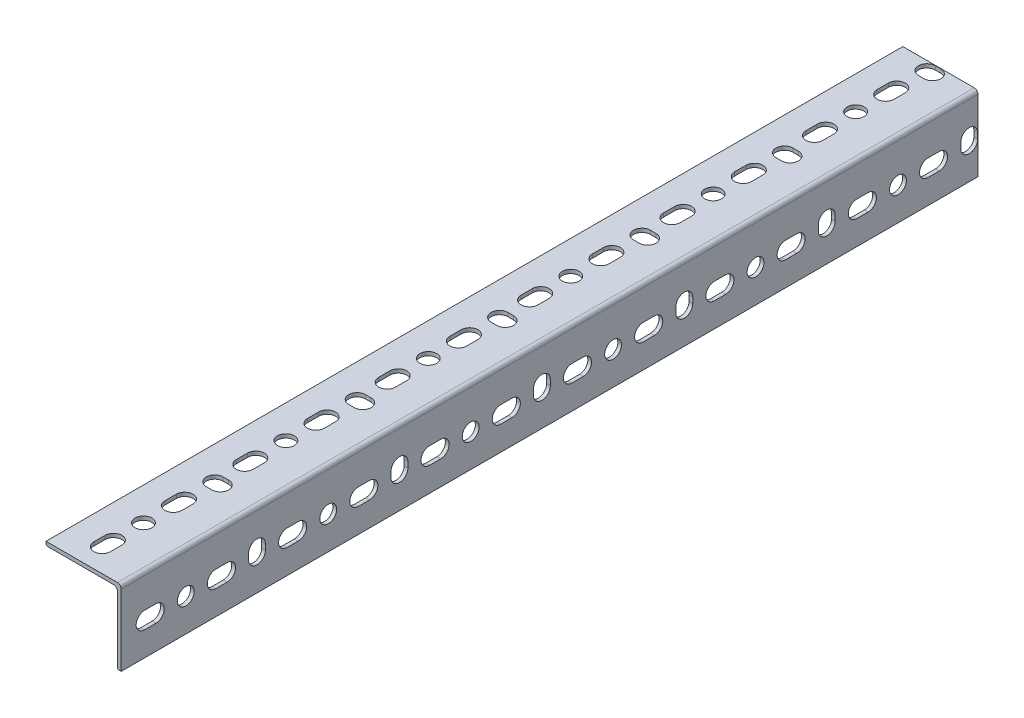
from build123d import *

# Parameters (mm, degrees)
STRUCTURAL_MEMBER1_DEPTH         = 457.2
SLOT_DEPTH                       = 461.703657463
SKETCH4_R                        = 4.5
HOLE_DEPTH                       = 461.703657463
VERT_SLOT_DEPTH                  = 461.703657463
SLOT_PATTERN_COUNT               = 12
SLOT_PATTERN_PITCH               = 38
HOLE_PATTERN_COUNT               = 6
HOLE_PATTERN_PITCH               = 76
LPATTERN1_COUNT                  = 6
LPATTERN1_PITCH                  = 76
OTHER_SIDE_CUTS_COUNT            = 2
OTHER_SIDE_CUTS_ANGLE            = 90
OTHER_SIDE_CUTS_COPY_1_DEPTH     = 461.703657463
OTHER_SIDE_CUTS_COPY_2_DEPTH     = 461.703657463
OTHER_SIDE_CUTS_COPY_3_DEPTH     = 461.703657463
OTHER_SIDE_CUTS_COPY_4_DEPTH     = 461.703657463
OTHER_SIDE_CUTS_COPY_5_DEPTH     = 461.703657463
OTHER_SIDE_CUTS_COPY_6_DEPTH     = 461.703657463
OTHER_SIDE_CUTS_COPY_7_DEPTH     = 461.703657463
OTHER_SIDE_CUTS_COPY_8_DEPTH     = 461.703657463
OTHER_SIDE_CUTS_COPY_9_DEPTH     = 461.703657463
OTHER_SIDE_CUTS_COPY_10_DEPTH    = 461.703657463
OTHER_SIDE_CUTS_COPY_11_DEPTH    = 461.703657463
OTHER_SIDE_CUTS_COPY_12_SKETCH_R = 4.5
OTHER_SIDE_CUTS_COPY_12_DEPTH    = 461.703657463
OTHER_SIDE_CUTS_COPY_13_SKETCH_R = 4.5
OTHER_SIDE_CUTS_COPY_13_DEPTH    = 461.703657463
OTHER_SIDE_CUTS_COPY_14_SKETCH_R = 4.5
OTHER_SIDE_CUTS_COPY_14_DEPTH    = 461.703657463
OTHER_SIDE_CUTS_COPY_15_SKETCH_R = 4.5
OTHER_SIDE_CUTS_COPY_15_DEPTH    = 461.703657463
OTHER_SIDE_CUTS_COPY_16_SKETCH_R = 4.5
OTHER_SIDE_CUTS_COPY_16_DEPTH    = 461.703657463
OTHER_SIDE_CUTS_COPY_17_DEPTH    = 461.703657463
OTHER_SIDE_CUTS_COPY_18_DEPTH    = 461.703657463
OTHER_SIDE_CUTS_COPY_19_DEPTH    = 461.703657463
OTHER_SIDE_CUTS_COPY_20_DEPTH    = 461.703657463
OTHER_SIDE_CUTS_COPY_21_DEPTH    = 461.703657463


with BuildPart() as part:
    # Sketch13 → Structural Member1 (new body)
    with BuildSketch(Plane(origin=(0, 0, 0), x_dir=(-1, 0, 0), z_dir=(0, 0, -1))):
        with BuildLine():
            Line((40.1, 0), (2, 0))
            ThreePointArc((2, 0), (0.585786438, -0.585786438), (0, -2))
            Line((0, -2), (0, -40.1))
            Line((0, -40.1), (1, -40.1))
            ThreePointArc((1, -40.1), (1.707106781, -39.807106781), (2, -39.1))
            Line((2, -39.1), (2, -4))
            ThreePointArc((2, -4), (2.585786438, -2.585786438), (4, -2))
            Line((4, -2), (39.1, -2))
            ThreePointArc((39.1, -2), (39.807106781, -1.707106781), (40.1, -1))
            Line((40.1, -1), (40.1, 0))
        make_face()
    extrude(amount=STRUCTURAL_MEMBER1_DEPTH)

    # Sketch3 → Slot (cut, through all)
    with BuildSketch(Plane(origin=(0, 0, 0), x_dir=(1, 0, 0), z_dir=(0, 1, 0))):
        with BuildLine():
            Line((-27.1, 12.5), (-27.1, 18.5))
            ThreePointArc((-27.1, 18.5), (-22.6, 23), (-18.1, 18.5))
            Line((-18.1, 18.5), (-18.1, 12.5))
            ThreePointArc((-18.1, 12.5), (-22.6, 8), (-27.1, 12.5))
        make_face()
    slot = extrude(amount=-SLOT_DEPTH, mode=Mode.SUBTRACT)

    # Sketch4 → Hole (cut, through all)
    with BuildSketch(Plane(origin=(0, 0, 0), x_dir=(1, 0, 0), z_dir=(0, 1, 0))):
        with Locations(Location((-22.6, 34.5, 0), (0, 0, 180))):
            Circle(SKETCH4_R)
    hole = extrude(amount=-HOLE_DEPTH, mode=Mode.SUBTRACT)

    # Sketch14 → Vert Slot (cut, through all)
    with BuildSketch(Plane(origin=(0, 0, 0), x_dir=(1, 0, 0), z_dir=(0, 1, 0))):
        with BuildLine():
            Line((-19.6, 68), (-22.6, 68))
            ThreePointArc((-22.6, 68), (-27.1, 72.5), (-22.6, 77))
            Line((-22.6, 77), (-19.6, 77))
            ThreePointArc((-19.6, 77), (-15.1, 72.5), (-19.6, 68))
        make_face()
    vert_slot = extrude(amount=-VERT_SLOT_DEPTH, mode=Mode.SUBTRACT)

    # Slot Pattern: Slot ×12
    with Locations(*[(0, 0, -i * SLOT_PATTERN_PITCH) for i in range(1, SLOT_PATTERN_COUNT)]):
        add(slot, mode=Mode.SUBTRACT)

    # Hole Pattern: Hole ×6
    with Locations(*[(0, 0, -i * HOLE_PATTERN_PITCH) for i in range(1, HOLE_PATTERN_COUNT)]):
        add(hole, mode=Mode.SUBTRACT)

    # LPattern1: Vert Slot ×6
    with Locations(*[(0, 0, -i * LPATTERN1_PITCH) for i in range(1, LPATTERN1_COUNT)]):
        add(vert_slot, mode=Mode.SUBTRACT)

    # Other side cuts: Slot, Hole, Vert Slot ×2 about axis
    other_side_cuts_axis = Axis((-4, -4, 0), (0, 0, 1))
    add([slot.rotate(other_side_cuts_axis, i * OTHER_SIDE_CUTS_ANGLE / (OTHER_SIDE_CUTS_COUNT - 1)) for i in range(1, OTHER_SIDE_CUTS_COUNT)], mode=Mode.SUBTRACT)
    add([hole.rotate(other_side_cuts_axis, i * OTHER_SIDE_CUTS_ANGLE / (OTHER_SIDE_CUTS_COUNT - 1)) for i in range(1, OTHER_SIDE_CUTS_COUNT)], mode=Mode.SUBTRACT)
    add([vert_slot.rotate(other_side_cuts_axis, i * OTHER_SIDE_CUTS_ANGLE / (OTHER_SIDE_CUTS_COUNT - 1)) for i in range(1, OTHER_SIDE_CUTS_COUNT)], mode=Mode.SUBTRACT)

    # Other side cuts copy 1 sketch → Other side cuts copy 1 (cut, through all)
    with BuildSketch(Plane(origin=(-8, 0, -38), x_dir=(0, 1, 0), z_dir=(-1, 0, 0))):
        with BuildLine():
            Line((-27.1, 12.5), (-27.1, 18.5))
            ThreePointArc((-27.1, 18.5), (-22.6, 23), (-18.1, 18.5))
            Line((-18.1, 18.5), (-18.1, 12.5))
            ThreePointArc((-18.1, 12.5), (-22.6, 8), (-27.1, 12.5))
        make_face()
    extrude(amount=-OTHER_SIDE_CUTS_COPY_1_DEPTH, mode=Mode.SUBTRACT)

    # Other side cuts copy 2 sketch → Other side cuts copy 2 (cut, through all)
    with BuildSketch(Plane(origin=(-8, 0, -76), x_dir=(0, 1, 0), z_dir=(-1, 0, 0))):
        with BuildLine():
            Line((-27.1, 12.5), (-27.1, 18.5))
            ThreePointArc((-27.1, 18.5), (-22.6, 23), (-18.1, 18.5))
            Line((-18.1, 18.5), (-18.1, 12.5))
            ThreePointArc((-18.1, 12.5), (-22.6, 8), (-27.1, 12.5))
        make_face()
    extrude(amount=-OTHER_SIDE_CUTS_COPY_2_DEPTH, mode=Mode.SUBTRACT)

    # Other side cuts copy 3 sketch → Other side cuts copy 3 (cut, through all)
    with BuildSketch(Plane(origin=(-8, 0, -114), x_dir=(0, 1, 0), z_dir=(-1, 0, 0))):
        with BuildLine():
            Line((-27.1, 12.5), (-27.1, 18.5))
            ThreePointArc((-27.1, 18.5), (-22.6, 23), (-18.1, 18.5))
            Line((-18.1, 18.5), (-18.1, 12.5))
            ThreePointArc((-18.1, 12.5), (-22.6, 8), (-27.1, 12.5))
        make_face()
    extrude(amount=-OTHER_SIDE_CUTS_COPY_3_DEPTH, mode=Mode.SUBTRACT)

    # Other side cuts copy 4 sketch → Other side cuts copy 4 (cut, through all)
    with BuildSketch(Plane(origin=(-8, 0, -152), x_dir=(0, 1, 0), z_dir=(-1, 0, 0))):
        with BuildLine():
            Line((-27.1, 12.5), (-27.1, 18.5))
            ThreePointArc((-27.1, 18.5), (-22.6, 23), (-18.1, 18.5))
            Line((-18.1, 18.5), (-18.1, 12.5))
            ThreePointArc((-18.1, 12.5), (-22.6, 8), (-27.1, 12.5))
        make_face()
    extrude(amount=-OTHER_SIDE_CUTS_COPY_4_DEPTH, mode=Mode.SUBTRACT)

    # Other side cuts copy 5 sketch → Other side cuts copy 5 (cut, through all)
    with BuildSketch(Plane(origin=(-8, 0, -190), x_dir=(0, 1, 0), z_dir=(-1, 0, 0))):
        with BuildLine():
            Line((-27.1, 12.5), (-27.1, 18.5))
            ThreePointArc((-27.1, 18.5), (-22.6, 23), (-18.1, 18.5))
            Line((-18.1, 18.5), (-18.1, 12.5))
            ThreePointArc((-18.1, 12.5), (-22.6, 8), (-27.1, 12.5))
        make_face()
    extrude(amount=-OTHER_SIDE_CUTS_COPY_5_DEPTH, mode=Mode.SUBTRACT)

    # Other side cuts copy 6 sketch → Other side cuts copy 6 (cut, through all)
    with BuildSketch(Plane(origin=(-8, 0, -228), x_dir=(0, 1, 0), z_dir=(-1, 0, 0))):
        with BuildLine():
            Line((-27.1, 12.5), (-27.1, 18.5))
            ThreePointArc((-27.1, 18.5), (-22.6, 23), (-18.1, 18.5))
            Line((-18.1, 18.5), (-18.1, 12.5))
            ThreePointArc((-18.1, 12.5), (-22.6, 8), (-27.1, 12.5))
        make_face()
    extrude(amount=-OTHER_SIDE_CUTS_COPY_6_DEPTH, mode=Mode.SUBTRACT)

    # Other side cuts copy 7 sketch → Other side cuts copy 7 (cut, through all)
    with BuildSketch(Plane(origin=(-8, 0, -266), x_dir=(0, 1, 0), z_dir=(-1, 0, 0))):
        with BuildLine():
            Line((-27.1, 12.5), (-27.1, 18.5))
            ThreePointArc((-27.1, 18.5), (-22.6, 23), (-18.1, 18.5))
            Line((-18.1, 18.5), (-18.1, 12.5))
            ThreePointArc((-18.1, 12.5), (-22.6, 8), (-27.1, 12.5))
        make_face()
    extrude(amount=-OTHER_SIDE_CUTS_COPY_7_DEPTH, mode=Mode.SUBTRACT)

    # Other side cuts copy 8 sketch → Other side cuts copy 8 (cut, through all)
    with BuildSketch(Plane(origin=(-8, 0, -304), x_dir=(0, 1, 0), z_dir=(-1, 0, 0))):
        with BuildLine():
            Line((-27.1, 12.5), (-27.1, 18.5))
            ThreePointArc((-27.1, 18.5), (-22.6, 23), (-18.1, 18.5))
            Line((-18.1, 18.5), (-18.1, 12.5))
            ThreePointArc((-18.1, 12.5), (-22.6, 8), (-27.1, 12.5))
        make_face()
    extrude(amount=-OTHER_SIDE_CUTS_COPY_8_DEPTH, mode=Mode.SUBTRACT)

    # Other side cuts copy 9 sketch → Other side cuts copy 9 (cut, through all)
    with BuildSketch(Plane(origin=(-8, 0, -342), x_dir=(0, 1, 0), z_dir=(-1, 0, 0))):
        with BuildLine():
            Line((-27.1, 12.5), (-27.1, 18.5))
            ThreePointArc((-27.1, 18.5), (-22.6, 23), (-18.1, 18.5))
            Line((-18.1, 18.5), (-18.1, 12.5))
            ThreePointArc((-18.1, 12.5), (-22.6, 8), (-27.1, 12.5))
        make_face()
    extrude(amount=-OTHER_SIDE_CUTS_COPY_9_DEPTH, mode=Mode.SUBTRACT)

    # Other side cuts copy 10 sketch → Other side cuts copy 10 (cut, through all)
    with BuildSketch(Plane(origin=(-8, 0, -380), x_dir=(0, 1, 0), z_dir=(-1, 0, 0))):
        with BuildLine():
            Line((-27.1, 12.5), (-27.1, 18.5))
            ThreePointArc((-27.1, 18.5), (-22.6, 23), (-18.1, 18.5))
            Line((-18.1, 18.5), (-18.1, 12.5))
            ThreePointArc((-18.1, 12.5), (-22.6, 8), (-27.1, 12.5))
        make_face()
    extrude(amount=-OTHER_SIDE_CUTS_COPY_10_DEPTH, mode=Mode.SUBTRACT)

    # Other side cuts copy 11 sketch → Other side cuts copy 11 (cut, through all)
    with BuildSketch(Plane(origin=(-8, 0, -418), x_dir=(0, 1, 0), z_dir=(-1, 0, 0))):
        with BuildLine():
            Line((-27.1, 12.5), (-27.1, 18.5))
            ThreePointArc((-27.1, 18.5), (-22.6, 23), (-18.1, 18.5))
            Line((-18.1, 18.5), (-18.1, 12.5))
            ThreePointArc((-18.1, 12.5), (-22.6, 8), (-27.1, 12.5))
        make_face()
    extrude(amount=-OTHER_SIDE_CUTS_COPY_11_DEPTH, mode=Mode.SUBTRACT)

    # Other side cuts copy 12 sketch → Other side cuts copy 12 (cut, through all)
    with BuildSketch(Plane(origin=(-8, 0, -76), x_dir=(0, 1, 0), z_dir=(-1, 0, 0))):
        with Locations(Location((-22.6, 34.5, 0), (0, 0, 180))):
            Circle(OTHER_SIDE_CUTS_COPY_12_SKETCH_R)
    extrude(amount=-OTHER_SIDE_CUTS_COPY_12_DEPTH, mode=Mode.SUBTRACT)

    # Other side cuts copy 13 sketch → Other side cuts copy 13 (cut, through all)
    with BuildSketch(Plane(origin=(-8, 0, -152), x_dir=(0, 1, 0), z_dir=(-1, 0, 0))):
        with Locations(Location((-22.6, 34.5, 0), (0, 0, 180))):
            Circle(OTHER_SIDE_CUTS_COPY_13_SKETCH_R)
    extrude(amount=-OTHER_SIDE_CUTS_COPY_13_DEPTH, mode=Mode.SUBTRACT)

    # Other side cuts copy 14 sketch → Other side cuts copy 14 (cut, through all)
    with BuildSketch(Plane(origin=(-8, 0, -228), x_dir=(0, 1, 0), z_dir=(-1, 0, 0))):
        with Locations(Location((-22.6, 34.5, 0), (0, 0, 180))):
            Circle(OTHER_SIDE_CUTS_COPY_14_SKETCH_R)
    extrude(amount=-OTHER_SIDE_CUTS_COPY_14_DEPTH, mode=Mode.SUBTRACT)

    # Other side cuts copy 15 sketch → Other side cuts copy 15 (cut, through all)
    with BuildSketch(Plane(origin=(-8, 0, -304), x_dir=(0, 1, 0), z_dir=(-1, 0, 0))):
        with Locations(Location((-22.6, 34.5, 0), (0, 0, 180))):
            Circle(OTHER_SIDE_CUTS_COPY_15_SKETCH_R)
    extrude(amount=-OTHER_SIDE_CUTS_COPY_15_DEPTH, mode=Mode.SUBTRACT)

    # Other side cuts copy 16 sketch → Other side cuts copy 16 (cut, through all)
    with BuildSketch(Plane(origin=(-8, 0, -380), x_dir=(0, 1, 0), z_dir=(-1, 0, 0))):
        with Locations(Location((-22.6, 34.5, 0), (0, 0, 180))):
            Circle(OTHER_SIDE_CUTS_COPY_16_SKETCH_R)
    extrude(amount=-OTHER_SIDE_CUTS_COPY_16_DEPTH, mode=Mode.SUBTRACT)

    # Other side cuts copy 17 sketch → Other side cuts copy 17 (cut, through all)
    with BuildSketch(Plane(origin=(-8, 0, -76), x_dir=(0, 1, 0), z_dir=(-1, 0, 0))):
        with BuildLine():
            Line((-19.6, 68), (-22.6, 68))
            ThreePointArc((-22.6, 68), (-27.1, 72.5), (-22.6, 77))
            Line((-22.6, 77), (-19.6, 77))
            ThreePointArc((-19.6, 77), (-15.1, 72.5), (-19.6, 68))
        make_face()
    extrude(amount=-OTHER_SIDE_CUTS_COPY_17_DEPTH, mode=Mode.SUBTRACT)

    # Other side cuts copy 18 sketch → Other side cuts copy 18 (cut, through all)
    with BuildSketch(Plane(origin=(-8, 0, -152), x_dir=(0, 1, 0), z_dir=(-1, 0, 0))):
        with BuildLine():
            Line((-19.6, 68), (-22.6, 68))
            ThreePointArc((-22.6, 68), (-27.1, 72.5), (-22.6, 77))
            Line((-22.6, 77), (-19.6, 77))
            ThreePointArc((-19.6, 77), (-15.1, 72.5), (-19.6, 68))
        make_face()
    extrude(amount=-OTHER_SIDE_CUTS_COPY_18_DEPTH, mode=Mode.SUBTRACT)

    # Other side cuts copy 19 sketch → Other side cuts copy 19 (cut, through all)
    with BuildSketch(Plane(origin=(-8, 0, -228), x_dir=(0, 1, 0), z_dir=(-1, 0, 0))):
        with BuildLine():
            Line((-19.6, 68), (-22.6, 68))
            ThreePointArc((-22.6, 68), (-27.1, 72.5), (-22.6, 77))
            Line((-22.6, 77), (-19.6, 77))
            ThreePointArc((-19.6, 77), (-15.1, 72.5), (-19.6, 68))
        make_face()
    extrude(amount=-OTHER_SIDE_CUTS_COPY_19_DEPTH, mode=Mode.SUBTRACT)

    # Other side cuts copy 20 sketch → Other side cuts copy 20 (cut, through all)
    with BuildSketch(Plane(origin=(-8, 0, -304), x_dir=(0, 1, 0), z_dir=(-1, 0, 0))):
        with BuildLine():
            Line((-19.6, 68), (-22.6, 68))
            ThreePointArc((-22.6, 68), (-27.1, 72.5), (-22.6, 77))
            Line((-22.6, 77), (-19.6, 77))
            ThreePointArc((-19.6, 77), (-15.1, 72.5), (-19.6, 68))
        make_face()
    extrude(amount=-OTHER_SIDE_CUTS_COPY_20_DEPTH, mode=Mode.SUBTRACT)

    # Other side cuts copy 21 sketch → Other side cuts copy 21 (cut, through all)
    with BuildSketch(Plane(origin=(-8, 0, -380), x_dir=(0, 1, 0), z_dir=(-1, 0, 0))):
        with BuildLine():
            Line((-19.6, 68), (-22.6, 68))
            ThreePointArc((-22.6, 68), (-27.1, 72.5), (-22.6, 77))
            Line((-22.6, 77), (-19.6, 77))
            ThreePointArc((-19.6, 77), (-15.1, 72.5), (-19.6, 68))
        make_face()
    extrude(amount=-OTHER_SIDE_CUTS_COPY_21_DEPTH, mode=Mode.SUBTRACT)


solid = part.part
